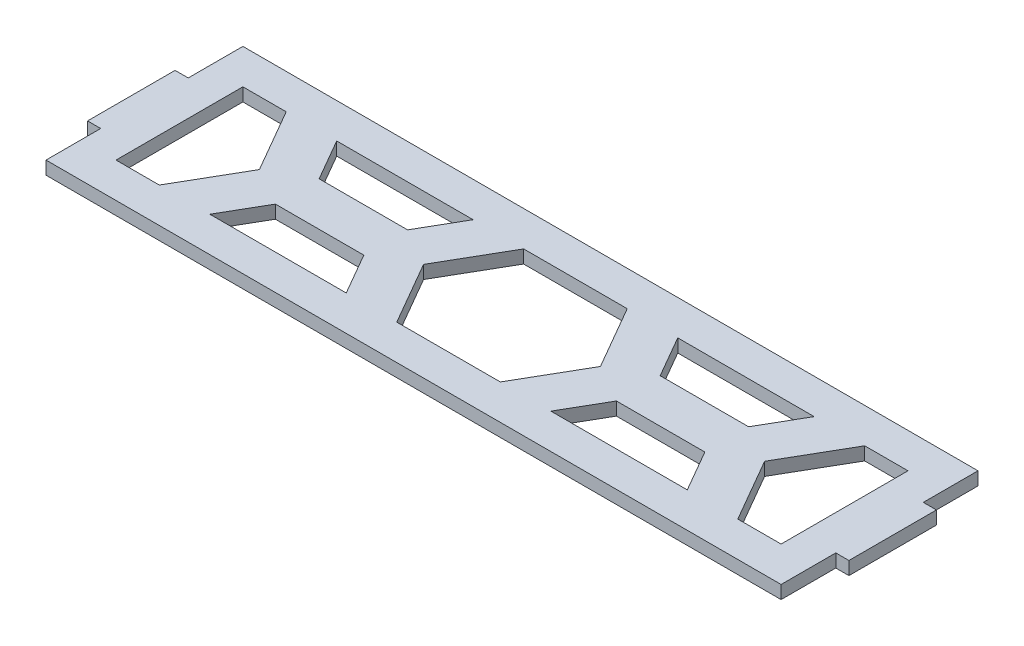
from build123d import *

# Parameters (mm, degrees)
BOSS_EXTRUDE1_DEPTH     = 1.5
CUT_EXTRUDE1_DEPTH      = 2.5
CUT_EXTRUDE1_DEPTH_BACK = 2.5


with BuildPart() as part:
    # Sketch1 → Boss-Extrude1 (new body, symmetric)
    with BuildSketch(Plane(origin=(0, 0, 0), x_dir=(1, 0, 0), z_dir=(0, 1, 0))):
        Polygon((-87, 10), (-87, -10), (-84, -10), (-84, -22.5), (84, -22.5), (84, -10), (87, -10), (87, 10), (84, 10), (84, 22.5), (-84, 22.5), (-84, 10), align=None)
    extrude(amount=BOSS_EXTRUDE1_DEPTH, both=True)

    # Sketch3 → Cut-Extrude1 (cut, two sides)
    with BuildSketch(Plane(origin=(0, 0, 0), x_dir=(1, 0, 0), z_dir=(0, 1, 0))) as cut_extrude1_sk:
        Polygon((-76, -14.5), (-66.106605822, -14.5), (-57.735026919, 0), (-66.106605822, 14.5), (-76, 14.5), align=None)
        Polygon((-20.207259422, 0), (-11.835680518, -14.5), (11.835680518, -14.5), (20.207259422, 0), (11.835680518, 14.5), (-11.835680518, 14.5), align=None)
        Polygon((57.735026919, 0), (66.106605822, -14.5), (76, -14.5), (76, 14.5), (66.106605822, 14.5), align=None)
        Polygon((28.867513459, -5), (23.382685902, -14.5), (54.559600438, -14.5), (49.074772881, -5), align=None)
        Polygon((54.559600438, 14.5), (23.382685902, 14.5), (28.867513459, 5), (49.074772881, 5), align=None)
        Polygon((-49.074772881, -5), (-54.559600438, -14.5), (-23.382685902, -14.5), (-28.867513459, -5), align=None)
        Polygon((-23.382685902, 14.5), (-54.559600438, 14.5), (-49.074772881, 5), (-28.867513459, 5), align=None)
    extrude(amount=CUT_EXTRUDE1_DEPTH, mode=Mode.SUBTRACT)
    extrude(cut_extrude1_sk.sketch, amount=-CUT_EXTRUDE1_DEPTH_BACK, mode=Mode.SUBTRACT)


solid = part.part
